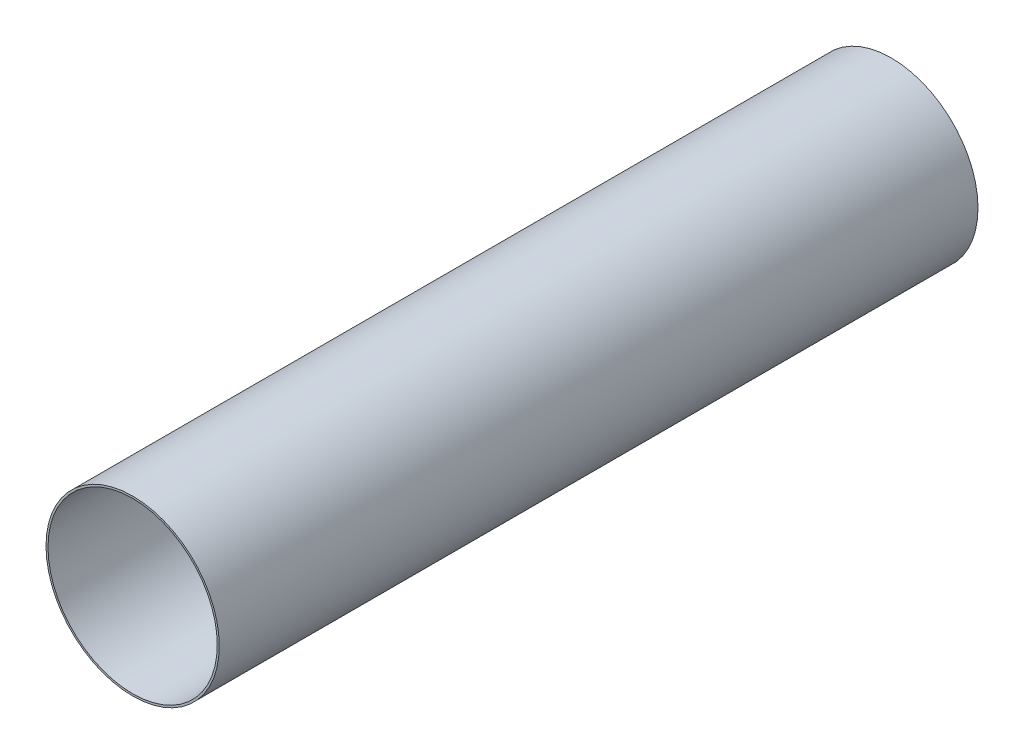
from build123d import *

# Parameters (mm, degrees)
SKETCH1_R           = 86.99983
SKETCH1_R_2         = 84.99983
BOSS_EXTRUDE1_DEPTH = 381


with BuildPart() as part:
    # Sketch1 → Boss-Extrude1 (new body, symmetric)
    with BuildSketch(Plane.XY):
        Circle(SKETCH1_R)
        Circle(SKETCH1_R_2, mode=Mode.SUBTRACT)
    extrude(amount=BOSS_EXTRUDE1_DEPTH, both=True)


solid = part.part
